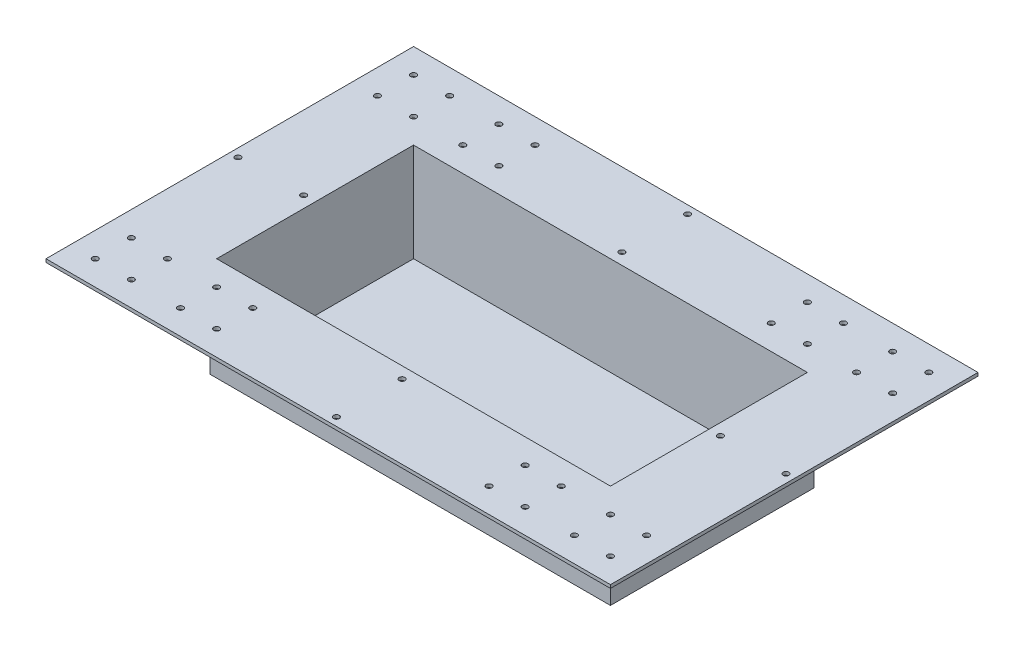
from build123d import *

# Parameters (mm, degrees)
SKETCH1_W           = 619.76
SKETCH1_H           = 314.96
SKETCH1_W_2         = 609.6
SKETCH1_H_2         = 304.8
EXTRUDE_THIN1_DEPTH = 152.4
SKETCH2_W           = 873.76
SKETCH2_H           = 568.96
SKETCH2_W_2         = 619.76
SKETCH2_H_2         = 314.96
BOSS_EXTRUDE1_DEPTH = 5.08
SKETCH3_W           = 619.76
SKETCH3_H           = 314.96
BOSS_EXTRUDE2_DEPTH = 2.54
SKETCH4_R           = 4.445
CUT_EXTRUDE1_DEPTH  = 155.94


with BuildPart() as part:
    # Sketch1 → Extrude-Thin1 (new body)
    with BuildSketch(Plane(origin=(0, 0, 0), x_dir=(1, 0, 0), z_dir=(0, 1, 0))):
        Rectangle(SKETCH1_W, SKETCH1_H)
        Rectangle(SKETCH1_W_2, SKETCH1_H_2, mode=Mode.SUBTRACT)
    extrude(amount=-EXTRUDE_THIN1_DEPTH)

    # Sketch2 → Boss-Extrude1 (add)
    with BuildSketch(Plane(origin=(0, 0, 0), x_dir=(1, 0, 0), z_dir=(0, 1, 0))):
        Rectangle(SKETCH2_W, SKETCH2_H)
        Rectangle(SKETCH2_W_2, SKETCH2_H_2, mode=Mode.SUBTRACT)
    extrude(amount=-BOSS_EXTRUDE1_DEPTH)

    # Sketch3 → Boss-Extrude2 (add)
    with BuildSketch(Plane.XZ.offset(152.4)):
        Rectangle(SKETCH3_W, SKETCH3_H)
    extrude(amount=BOSS_EXTRUDE2_DEPTH)

    # Sketch4 → Cut-Extrude1 (cut, through all)
    with BuildSketch(Plane(origin=(0, 0, 0), x_dir=(1, 0, 0), z_dir=(0, 1, 0))):
        with Locations((-398.78, 246.38)):
            Circle(SKETCH4_R)
        with Locations((-342.9, 246.38)):
            Circle(SKETCH4_R)
        with Locations((-342.9, 190.5)):
            Circle(SKETCH4_R)
        with Locations((-398.78, 190.5)):
            Circle(SKETCH4_R)
        with Locations((-266.7, 246.38)):
            Circle(SKETCH4_R)
        with Locations((-266.7, 190.5)):
            Circle(SKETCH4_R)
        with Locations((-210.82, 190.5)):
            Circle(SKETCH4_R)
        with Locations((-210.82, 246.38)):
            Circle(SKETCH4_R)
        with Locations((-210.82, -190.5)):
            Circle(SKETCH4_R)
        with Locations((-210.82, -246.38)):
            Circle(SKETCH4_R)
        with Locations((-266.7, -246.38)):
            Circle(SKETCH4_R)
        with Locations((-266.7, -190.5)):
            Circle(SKETCH4_R)
        with Locations((-398.78, -190.5)):
            Circle(SKETCH4_R)
        with Locations((-342.9, -190.5)):
            Circle(SKETCH4_R)
        with Locations((-342.9, -246.38)):
            Circle(SKETCH4_R)
        with Locations((-398.78, -246.38)):
            Circle(SKETCH4_R)
        with Locations((210.82, -246.38)):
            Circle(SKETCH4_R)
        with Locations((210.82, -190.5)):
            Circle(SKETCH4_R)
        with Locations((266.7, -190.5)):
            Circle(SKETCH4_R)
        with Locations((266.7, -246.38)):
            Circle(SKETCH4_R)
        with Locations((398.78, -246.38)):
            Circle(SKETCH4_R)
        with Locations((342.9, -246.38)):
            Circle(SKETCH4_R)
        with Locations((342.9, -190.5)):
            Circle(SKETCH4_R)
        with Locations((398.78, -190.5)):
            Circle(SKETCH4_R)
        with Locations((398.78, 190.5)):
            Circle(SKETCH4_R)
        with Locations((342.9, 190.5)):
            Circle(SKETCH4_R)
        with Locations((266.7, 190.5)):
            Circle(SKETCH4_R)
        with Locations((210.82, 190.5)):
            Circle(SKETCH4_R)
        with Locations((210.82, 246.38)):
            Circle(SKETCH4_R)
        with Locations((266.7, 246.38)):
            Circle(SKETCH4_R)
        with Locations((342.9, 246.38)):
            Circle(SKETCH4_R)
        with Locations((398.78, 246.38)):
            Circle(SKETCH4_R)
        with Locations((0, 271.78)):
            Circle(SKETCH4_R)
        with Locations((0, 170.18)):
            Circle(SKETCH4_R)
        with Locations((-424.18, 0)):
            Circle(SKETCH4_R)
        with Locations((-322.58, 0)):
            Circle(SKETCH4_R)
        with Locations((0, -271.78)):
            Circle(SKETCH4_R)
        with Locations((0, -170.18)):
            Circle(SKETCH4_R)
        with Locations((424.18, 0)):
            Circle(SKETCH4_R)
        with Locations((322.58, 0)):
            Circle(SKETCH4_R)
    extrude(amount=-CUT_EXTRUDE1_DEPTH, mode=Mode.SUBTRACT)


solid = part.part
